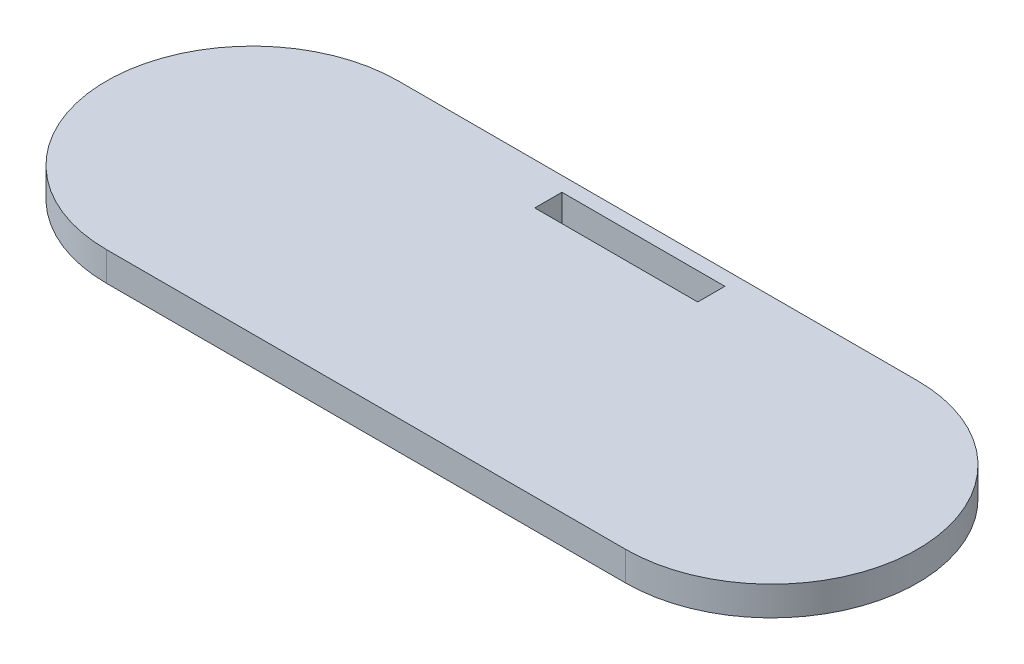
from build123d import *

# Parameters (mm, degrees)
SKETCH1_W           = 55.8
SKETCH1_H           = 9.3
BOSS_EXTRUDE1_DEPTH = 10


with BuildPart() as part:
    # Sketch1 → Boss-Extrude1 (new body)
    with BuildSketch(Plane(origin=(0, 0, 0), x_dir=(1, 0, 0), z_dir=(0, 1, 0))):
        with BuildLine():
            Line((0, 50), (177.8, 50))
            ThreePointArc((177.8, 50), (227.8, 0), (177.8, -50))
            Line((177.8, -50), (0, -50))
            ThreePointArc((0, -50), (-50, 0), (0, 50))
        make_face()
        with Locations((88.9, 40.35)):
            Rectangle(SKETCH1_W, SKETCH1_H, mode=Mode.SUBTRACT)
    extrude(amount=BOSS_EXTRUDE1_DEPTH)


solid = part.part
